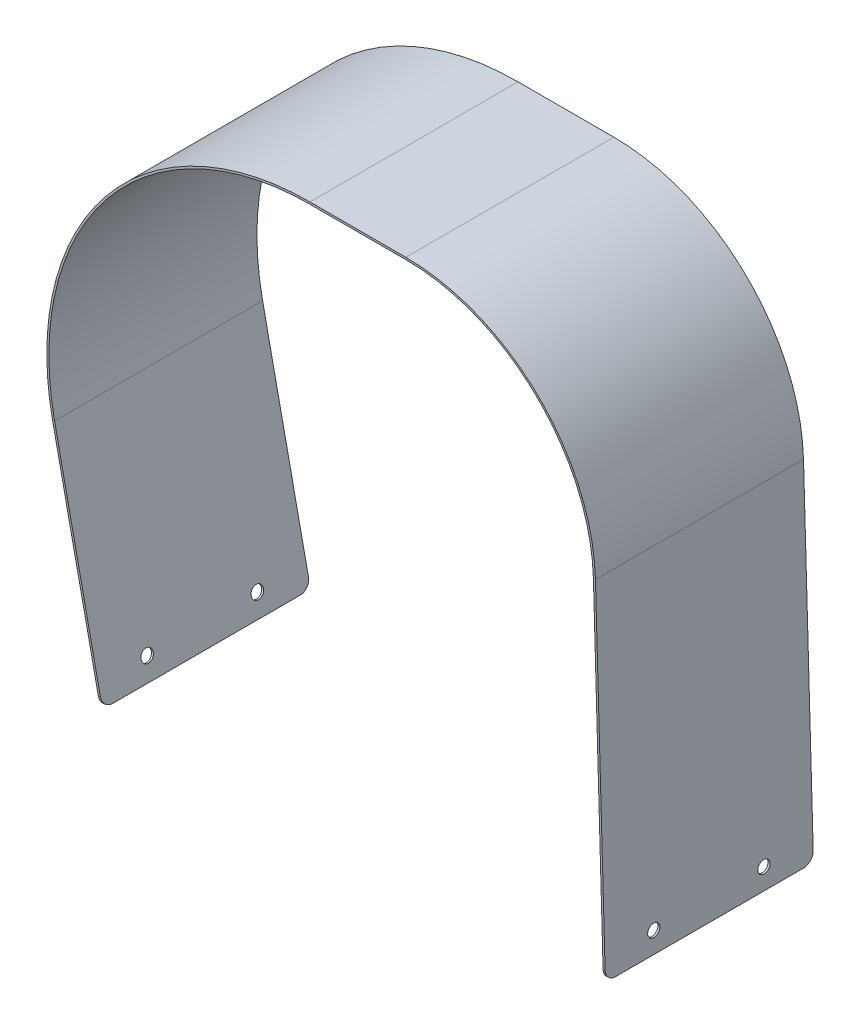
from build123d import *

# Parameters (mm, degrees)
WYCI_GNI_CIE_CIENKA_CIANKA1_DEPTH = 102
OTW_R1_D                          = 6
OTW_R1_DEPTH                      = 1
OTW_R2_D                          = 6
OTW_R2_DEPTH                      = 1
ZAOKR_GLENIE1_R                   = 5
OTW_R3_D                          = 6
OTW_R3_DEPTH                      = 1
OTW_R4_D                          = 6
OTW_R4_DEPTH                      = 1


with BuildPart() as part:
    # Szkic1 → Wyciągnięcie-cienka ścianka1 (new body)
    with BuildSketch(Plane.XY):
        with BuildLine():
            Line((134.043918698, -128), (129.158561205, 40.663670642))
            ThreePointArc((129.158561205, 40.663670642), (101.302286813, 103.988853979), (37.19712984, 130))
            Line((37.19712984, 130), (-9.80287016, 130))
            ThreePointArc((-9.80287016, 130), (-109.26340878, 82.570473856), (-135.015100263, -24.568730353))
            Line((-135.015100263, -24.568730353), (-111.522833189, -135.282306482))
            Line((-111.522833189, -135.282306482), (-112.501053736, -135.489874688))
            Line((-112.501053736, -135.489874688), (-135.993320811, -24.776298559))
            ThreePointArc((-135.993320811, -24.776298559), (-110.040444238, 83.199930683), (-9.80287016, 131))
            Line((-9.80287016, 131), (37.19712984, 131))
            ThreePointArc((37.19712984, 131), (101.999081998, 104.706124131), (130.158141981, 40.692623583))
            Line((130.158141981, 40.692623583), (135.043499474, -127.971047058))
            Line((135.043499474, -127.971047058), (134.043918698, -128))
        make_face()
    extrude(amount=WYCI_GNI_CIE_CIENKA_CIANKA1_DEPTH)

    # Otwór1
    with Locations(Plane(origin=(131.226711189, 3.800992794, 0), x_dir=(0, 0, -1), z_dir=(0.999580776, 0.028952942, 0))):
        with Locations((-78, -121.827305061)):
            Hole(OTW_R1_D / 2, depth=OTW_R1_DEPTH)

    # Otwór2
    with Locations(Plane(origin=(131.226711189, 3.800992794, 0), x_dir=(0, 0, -1), z_dir=(0.999580776, 0.028952942, 0))):
        with Locations((-24, -121.827305061)):
            Hole(OTW_R2_D / 2, depth=OTW_R2_DEPTH)

    # Zaokrąglenie1
    zaokr_glenie1_edges = [part.edges().sort_by_distance(p)[0] for p in [
        (134.543709086, -127.985523529, 0),
        (-112.011943462, -135.386090585, 0),
        (134.543709086, -127.985523529, 102),
        (-112.011943462, -135.386090585, 102),
    ]]
    fillet(zaokr_glenie1_edges, radius=ZAOKR_GLENIE1_R)

    # Otwór3
    with Locations(Plane(origin=(-135.164873494, -28.680577561, 0), x_dir=(0, 0, 1), z_dir=(-0.978220548, -0.207568206, 0))):
        with Locations((24, -99.187337539)):
            Hole(OTW_R3_D / 2, depth=OTW_R3_DEPTH)

    # Otwór4
    with Locations(Plane(origin=(-135.164873494, -28.680577561, 0), x_dir=(0, 0, 1), z_dir=(-0.978220548, -0.207568206, 0))):
        with Locations((78, -99.187337539)):
            Hole(OTW_R4_D / 2, depth=OTW_R4_DEPTH)


solid = part.part
